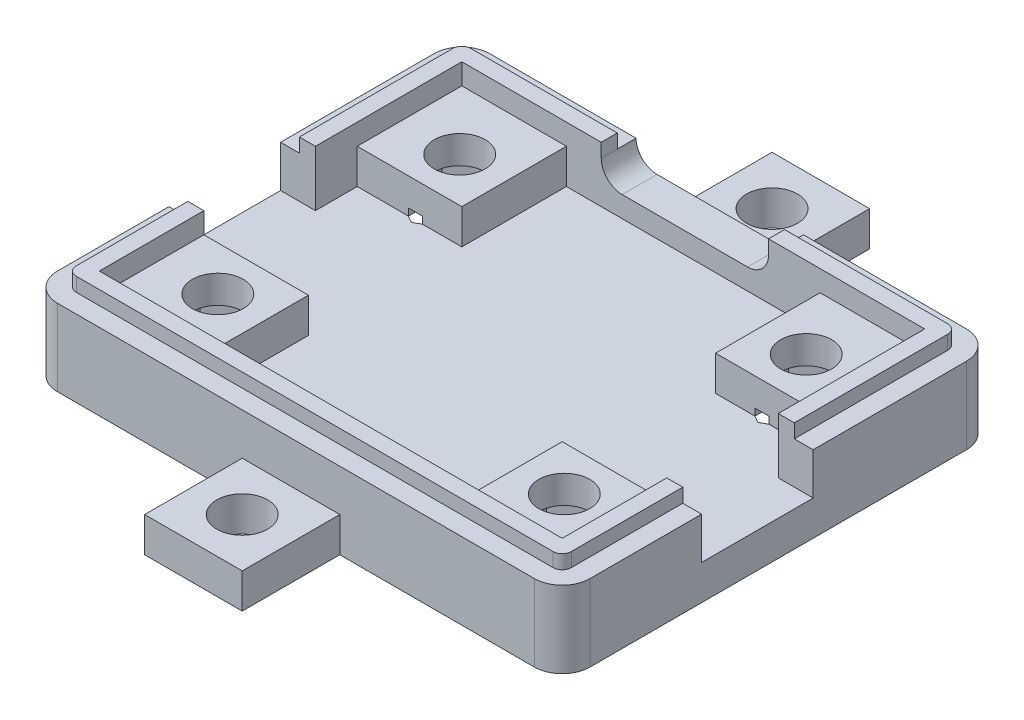
from build123d import *

# Parameters (mm, degrees)
BOSS_EXTRUDE1_DEPTH = 5.5
CUT_EXTRUDE1_DEPTH  = 3
SKETCH3_W           = 7.5
SKETCH3_H           = 7.5
CUT_EXTRUDE2_DEPTH  = 0.5
SKETCH4_R           = 1.825
CUT_EXTRUDE3_DEPTH  = 10
SKETCH5_W           = 2.5
SKETCH5_H           = 8
CUT_EXTRUDE4_DEPTH  = 3
SKETCH6_W           = 7
SKETCH6_H           = 7
SKETCH6_R           = 1.825
BOSS_EXTRUDE2_DEPTH = 2.5
BOSS_EXTRUDE3_DEPTH = 1
CUT_EXTRUDE6_DEPTH  = 4
SKETCH10_W          = 12
SKETCH10_H          = 2.5
CUT_EXTRUDE7_DEPTH  = 4
CUT_EXTRUDE8_DEPTH  = 3


with BuildPart() as part:
    # Sketch1 → Boss-Extrude1 (new body)
    with BuildSketch(Plane(origin=(0, 0, 0), x_dir=(1, 0, 0), z_dir=(0, 1, 0))):
        with BuildLine():
            Line((-17.1, -15.5), (17.1, -15.5))
            ThreePointArc((17.1, -15.5), (18.514213562, -14.914213562), (19.1, -13.5))
            Line((19.1, -13.5), (19.1, 13.5))
            ThreePointArc((19.1, 13.5), (18.514213562, 14.914213562), (17.1, 15.5))
            Line((17.1, 15.5), (-17.1, 15.5))
            ThreePointArc((-17.1, 15.5), (-18.514213562, 14.914213562), (-19.1, 13.5))
            Line((-19.1, 13.5), (-19.1, -13.5))
            ThreePointArc((-19.1, -13.5), (-18.514213562, -14.914213562), (-17.1, -15.5))
        make_face()
    extrude(amount=BOSS_EXTRUDE1_DEPTH)

    # Sketch2 → Cut-Extrude1 (cut)
    with BuildSketch(Plane(origin=(0, 5.5, 0), x_dir=(1, 0, 0), z_dir=(0, 1, 0))):
        Polygon((-16.6, 5.5), (-9.1, 5.5), (-9.1, 13), (9.1, 13), (9.1, 5.5), (16.6, 5.5), (16.6, -5.5), (9.1, -5.5), (9.1, -13), (-9.1, -13), (-9.1, -5.5), (-16.6, -5.5), align=None)
    extrude(amount=-CUT_EXTRUDE1_DEPTH, mode=Mode.SUBTRACT)

    # Sketch3 → Cut-Extrude2 (cut)
    with BuildSketch(Plane(origin=(0, 5.5, 0), x_dir=(1, 0, 0), z_dir=(0, 1, 0))):
        with Locations((-12.85, 9.25)):
            Rectangle(SKETCH3_W, SKETCH3_H)
        with Locations((12.85, 9.25)):
            Rectangle(SKETCH3_W, SKETCH3_H)
        with Locations((12.85, -9.25)):
            Rectangle(SKETCH3_W, SKETCH3_H)
        with Locations((-12.85, -9.25)):
            Rectangle(SKETCH3_W, SKETCH3_H)
    extrude(amount=-CUT_EXTRUDE2_DEPTH, mode=Mode.SUBTRACT)

    # Sketch4 → Cut-Extrude3 (cut)
    with BuildSketch(Plane(origin=(0, 5.5, 0), x_dir=(1, 0, 0), z_dir=(0, 1, 0))):
        with Locations(Location((-12.425, 8.675, 0), (0, 0, 270))):
            Circle(SKETCH4_R)
        with Locations(Location((12.425, 8.675, 0), (0, 0, 90))):
            Circle(SKETCH4_R)
        with Locations(Location((12.425, -8.675, 0), (0, 0, 270))):
            Circle(SKETCH4_R)
        with Locations(Location((-12.425, -8.675, 0), (0, 0, 270))):
            Circle(SKETCH4_R)
    extrude(amount=-CUT_EXTRUDE3_DEPTH, mode=Mode.SUBTRACT)

    # Sketch5 → Cut-Extrude4 (cut)
    with BuildSketch(Plane(origin=(0, 5.5, 0), x_dir=(1, 0, 0), z_dir=(0, 1, 0))):
        with Locations((-17.85, -1.5)):
            Rectangle(SKETCH5_W, SKETCH5_H)
        with Locations((17.85, -1.5)):
            Rectangle(SKETCH5_W, SKETCH5_H)
    extrude(amount=-CUT_EXTRUDE4_DEPTH, mode=Mode.SUBTRACT)

    # Sketch6 → Boss-Extrude2 (add)
    # profile 1 of 2: a face of its own
    with BuildSketch(Plane(origin=(0, 0, 0), x_dir=(1, 0, 0), z_dir=(0, 1, 0))):
        with Locations((-0.35, 19)):
            Rectangle(SKETCH6_W, SKETCH6_H)
        with Locations(Location((-0.35, 19, 0), (0, 0, 270))):
            Circle(SKETCH6_R, mode=Mode.SUBTRACT)
    # profile 2 of 2: a face of its own
    with BuildSketch(Plane(origin=(0, 0, 0), x_dir=(1, 0, 0), z_dir=(0, 1, 0))):
        with Locations((-0.35, -19)):
            Rectangle(SKETCH6_W, SKETCH6_H)
        with Locations(Location((-0.35, -19, 0), (0, 0, 90))):
            Circle(SKETCH6_R, mode=Mode.SUBTRACT)
    extrude(amount=BOSS_EXTRUDE2_DEPTH)

    # Sketch7 → Boss-Extrude3 (add)
    with BuildSketch(Plane(origin=(0, 5.5, 0), x_dir=(1, 0, 0), z_dir=(0, 1, 0))):
        with BuildLine():
            ThreePointArc((-17.1, -14.15), (-17.559619408, -13.959619408), (-17.75, -13.5))
            Line((-17.75, -13.5), (-17.75, -5.5))
            Line((-17.75, -5.5), (-16.6, -5.5))
            Line((-16.6, -5.5), (-16.6, -13))
            Line((-16.6, -13), (16.6, -13))
            Line((16.6, -13), (16.6, -5.5))
            Line((16.6, -5.5), (17.75, -5.5))
            Line((17.75, -5.5), (17.75, -13.5))
            ThreePointArc((17.75, -13.5), (17.559619408, -13.959619408), (17.1, -14.15))
            Line((17.1, -14.15), (-17.1, -14.15))
        make_face()
        with BuildLine():
            Line((16.6, 2.5), (17.75, 2.5))
            Line((17.75, 2.5), (17.75, 13.5))
            ThreePointArc((17.75, 13.5), (17.559619408, 13.959619408), (17.1, 14.15))
            Line((17.1, 14.15), (-17.1, 14.15))
            ThreePointArc((-17.1, 14.15), (-17.559619408, 13.959619408), (-17.75, 13.5))
            Line((-17.75, 13.5), (-17.75, 2.5))
            Line((-17.75, 2.5), (-16.6, 2.5))
            Line((-16.6, 2.5), (-16.6, 13))
            Line((-16.6, 13), (16.6, 13))
            Line((16.6, 13), (16.6, 2.5))
        make_face()
    extrude(amount=BOSS_EXTRUDE3_DEPTH)

    # Sketch9 → Cut-Extrude6 (cut)
    with BuildSketch(Plane(origin=(0, 0, -15.5), x_dir=(-1, 0, 0), z_dir=(0, 0, -1))):
        with BuildLine():
            Line((5.1, 4), (-3.9, 4))
            ThreePointArc((-3.9, 4), (-5.4, 5.5), (-3.9, 7))
            Line((-3.9, 7), (5.1, 7))
            ThreePointArc((5.1, 7), (6.6, 5.5), (5.1, 4))
        make_face()
    extrude(amount=-CUT_EXTRUDE6_DEPTH, mode=Mode.SUBTRACT)

    # Sketch10 → Cut-Extrude7 (cut)
    with BuildSketch(Plane(origin=(0, 5.5, 0), x_dir=(1, 0, 0), z_dir=(0, 1, 0))):
        with Locations((-0.6, 14.25)):
            Rectangle(SKETCH10_W, SKETCH10_H)
    extrude(amount=CUT_EXTRUDE7_DEPTH, mode=Mode.SUBTRACT)

    # Sketch12 → Cut-Extrude8 (cut)
    with BuildSketch(Plane.XZ):
        Polygon((-12.425, 12.139101615), (-15.425, 10.407050808), (-15.425, 6.942949192), (-12.425, 5.210898385), (-9.425, 6.942949192), (-9.425, 10.407050808), align=None)
        Polygon((9.425, 10.407050808), (12.425, 12.139101615), (15.425, 10.407050808), (15.425, 6.942949192), (12.425, 5.210898385), (9.425, 6.942949192), align=None)
        Polygon((12.425, -12.139101615), (15.425, -10.407050808), (15.425, -6.942949192), (12.425, -5.210898385), (9.425, -6.942949192), (9.425, -10.407050808), align=None)
        Polygon((-9.425, -10.407050808), (-12.425, -12.139101615), (-15.425, -10.407050808), (-15.425, -6.942949192), (-12.425, -5.210898385), (-9.425, -6.942949192), align=None)
    extrude(amount=-CUT_EXTRUDE8_DEPTH, mode=Mode.SUBTRACT)


solid = part.part
